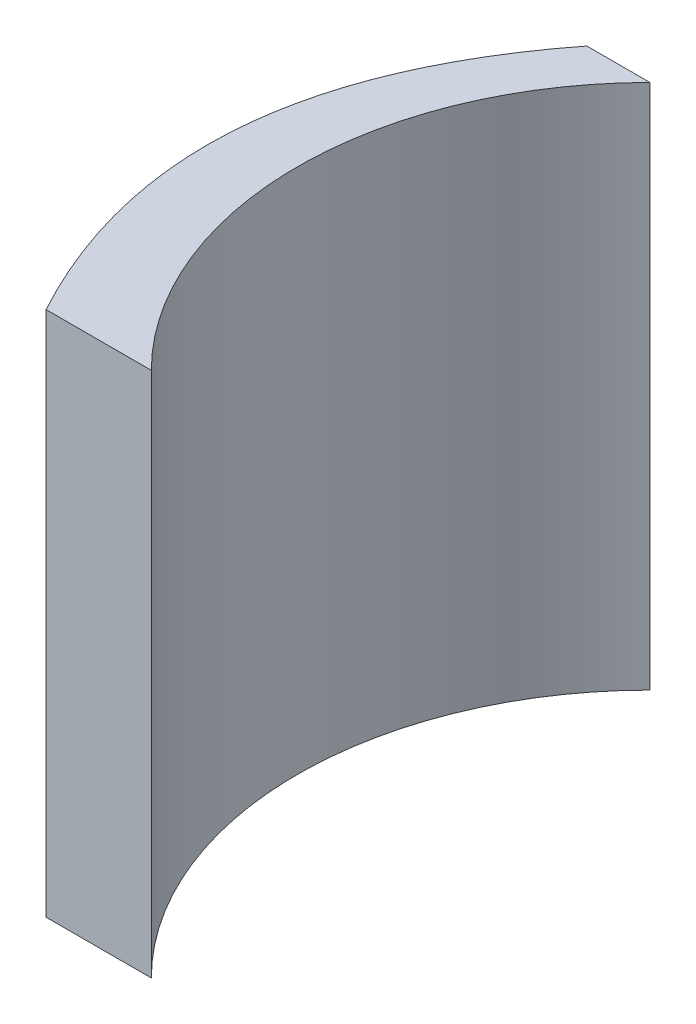
from build123d import *

# Parameters (mm, degrees)
BOSS_EXTRUDE1_DEPTH = 50
SKETCH3_W           = 8
SKETCH3_H           = 10
CUT_EXTRUDE5_DEPTH  = 18


with BuildPart() as part:
    # Sketch2 → Boss-Extrude1 (new body)
    with BuildSketch(Plane(origin=(0, 0, 0), x_dir=(1, 0, 0), z_dir=(0, 1, 0))):
        with BuildLine():
            ThreePointArc((-23.68807717, -23.68807717), (-33.5, 0), (-23.68807717, 23.68807717))
            Line((-23.68807717, 23.68807717), (-29.68807717, 23.68807717))
            add(Edge.make_bspline(
                [(-29.68807717, 23.68807717), (-47.221735333, 1.183613852), (-33.68807717, -23.68807717)],
                knots=[0, 0, 0, 1, 1, 1], degree=2))
            Line((-33.68807717, -23.68807717), (-23.68807717, -23.68807717))
        make_face()
    extrude(amount=BOSS_EXTRUDE1_DEPTH)

    # Sketch3 → Cut-Extrude5 (cut)
    with BuildSketch(Plane.XY.offset(23.68807717)):
        with Locations((-37.68807717, 12.5)):
            Rectangle(SKETCH3_W, SKETCH3_H)
    extrude(amount=-CUT_EXTRUDE5_DEPTH, mode=Mode.SUBTRACT)


solid = part.part
